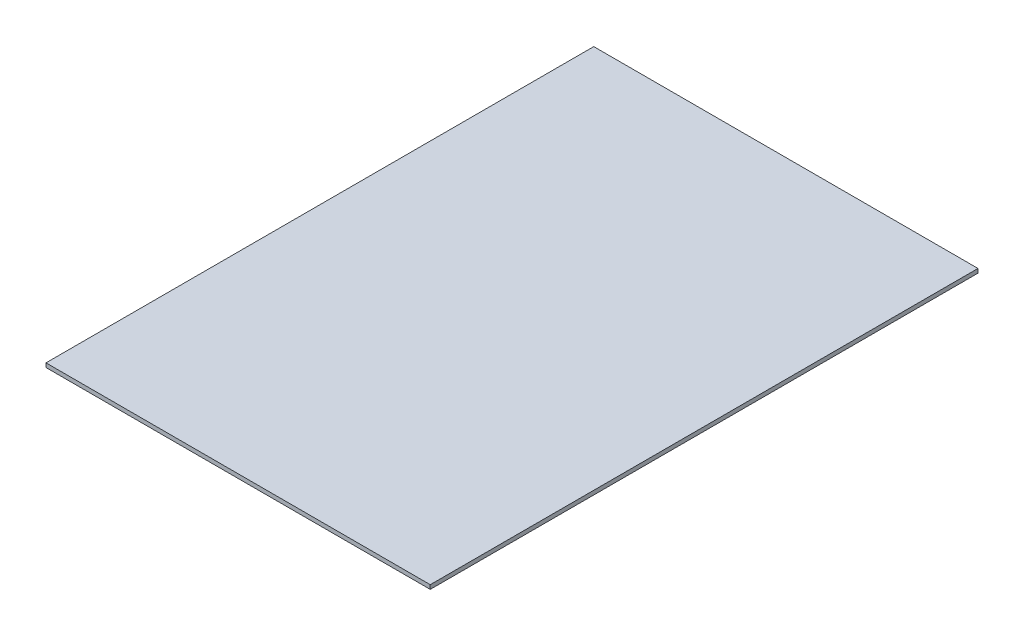
from build123d import *

# Parameters (mm, degrees)
SKETCH1_W           = 470
SKETCH1_H           = 670
BOSS_EXTRUDE1_DEPTH = 5


with BuildPart() as part:
    # Sketch1 → Boss-Extrude1 (new body)
    with BuildSketch(Plane(origin=(0, 0, 0), x_dir=(1, 0, 0), z_dir=(0, 1, 0))):
        with Locations((-235, 335)):
            Rectangle(SKETCH1_W, SKETCH1_H)
    extrude(amount=BOSS_EXTRUDE1_DEPTH)


solid = part.part
